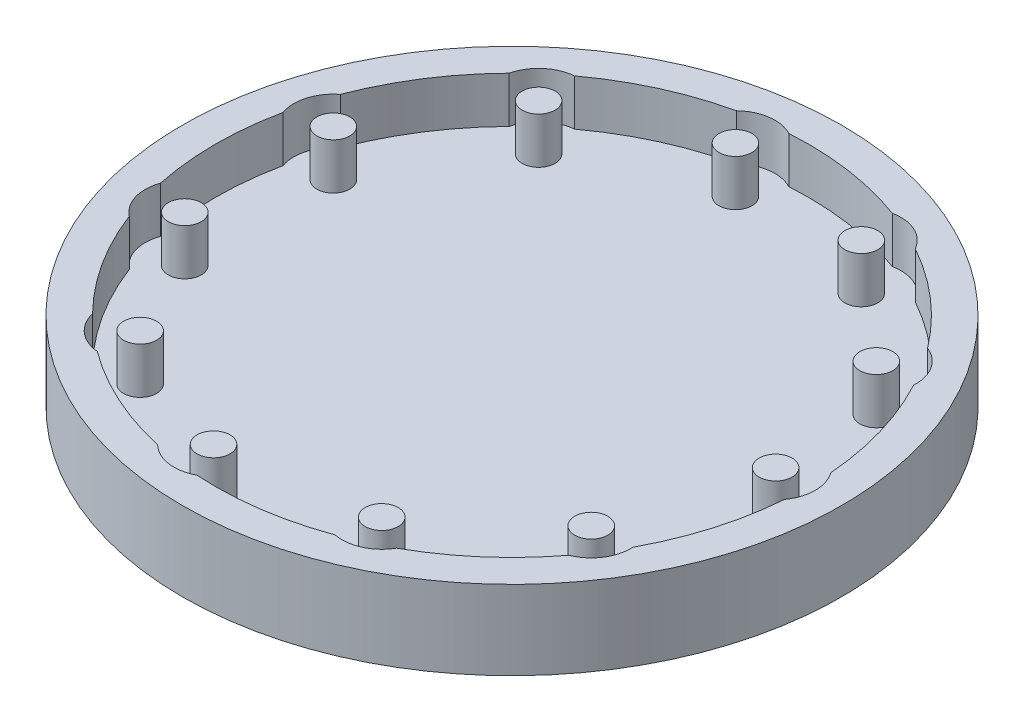
from build123d import *

# Parameters (mm, degrees)
SKETCH2_R           = 50
BOSS_EXTRUDE1_DEPTH = 5
SKETCH3_R           = 2.5
BOSS_EXTRUDE2_DEPTH = 7
SKETCH4_R           = 50
BOSS_EXTRUDE3_DEPTH = 7


with BuildPart() as part:
    # Sketch2 → Boss-Extrude1 (new body)
    with BuildSketch(Plane(origin=(0, 0, 0), x_dir=(1, 0, 0), z_dir=(0, 1, 0))):
        Circle(SKETCH2_R)
    extrude(amount=BOSS_EXTRUDE1_DEPTH)

    # Sketch3 → Boss-Extrude2 (add)
    with BuildSketch(Plane(origin=(0, 5, 0), x_dir=(1, 0, 0), z_dir=(0, 1, 0))):
        with Locations((40, 0)):
            Circle(SKETCH3_R)
        with Locations((33.650141313, -21.625632698)):
            Circle(SKETCH3_R)
        with Locations((16.61660052, -36.385279814)):
            Circle(SKETCH3_R)
        with Locations((-5.692593531, -39.592857675)):
            Circle(SKETCH3_R)
        with Locations((-26.194429358, -30.229982974)):
            Circle(SKETCH3_R)
        with Locations((-38.379718945, -11.269302274)):
            Circle(SKETCH3_R)
        with Locations((-38.379718945, 11.269302274)):
            Circle(SKETCH3_R)
        with Locations((-26.194429358, 30.229982974)):
            Circle(SKETCH3_R)
        with Locations((-5.692593531, 39.592857675)):
            Circle(SKETCH3_R)
        with Locations((16.61660052, 36.385279814)):
            Circle(SKETCH3_R)
        with Locations((33.650141313, 21.625632698)):
            Circle(SKETCH3_R)
    extrude(amount=BOSS_EXTRUDE2_DEPTH)

    # Sketch4 → Boss-Extrude3 (add)
    with BuildSketch(Plane(origin=(0, 5, 0), x_dir=(1, 0, 0), z_dir=(0, 1, 0))):
        Circle(SKETCH4_R)
        with BuildLine():
            ThreePointArc((44.8625, -3.515123575), (46, 0), (44.8625, 3.515123575))
            ThreePointArc((44.8625, 3.515123575), (43.177183813, 12.677965058), (39.6411559, 21.297388547))
            ThreePointArc((39.6411559, 21.297388547), (38.69766251, 24.869477603), (35.840317333, 27.211608799))
            ThreePointArc((35.840317333, 27.211608799), (29.468733028, 34.008730846), (21.834024893, 39.348130286))
            ThreePointArc((21.834024893, 39.348130286), (19.109090598, 41.843071786), (15.439087149, 42.268600497))
            ThreePointArc((15.439087149, 42.268600497), (6.404167722, 44.541964885), (-2.905254746, 44.90611868))
            ThreePointArc((-2.905254746, 44.90611868), (-6.546482561, 45.531786327), (-9.863944118, 43.905610193))
            ThreePointArc((-9.863944118, 43.905610193), (-18.693675585, 40.933439791), (-26.722136531, 36.206731684))
            ThreePointArc((-26.722136531, 36.206731684), (-30.123593761, 34.76448042), (-32.035242822, 31.602898875))
            ThreePointArc((-32.035242822, 31.602898875), (-37.856408977, 24.328836786), (-42.054928776, 16.011963203))
            ThreePointArc((-42.054928776, 16.011963203), (-44.136676786, 12.959697615), (-44.035578281, 9.266490459))
            ThreePointArc((-44.035578281, 9.266490459), (-45, 0), (-44.035578281, -9.266490459))
            ThreePointArc((-44.035578281, -9.266490459), (-44.136676786, -12.959697615), (-42.054928776, -16.011963203))
            ThreePointArc((-42.054928776, -16.011963203), (-37.856408977, -24.328836786), (-32.035242822, -31.602898875))
            ThreePointArc((-32.035242822, -31.602898875), (-30.123593761, -34.76448042), (-26.722136531, -36.206731684))
            ThreePointArc((-26.722136531, -36.206731684), (-18.693675585, -40.933439791), (-9.863944118, -43.905610193))
            ThreePointArc((-9.863944118, -43.905610193), (-6.546482561, -45.531786327), (-2.905254746, -44.90611868))
            ThreePointArc((-2.905254746, -44.90611868), (6.404167722, -44.541964885), (15.439087149, -42.268600497))
            ThreePointArc((15.439087149, -42.268600497), (19.109090598, -41.843071786), (21.834024893, -39.348130286))
            ThreePointArc((21.834024893, -39.348130286), (29.468733028, -34.008730846), (35.840317333, -27.211608799))
            ThreePointArc((35.840317333, -27.211608799), (38.69766251, -24.869477603), (39.6411559, -21.297388547))
            ThreePointArc((39.6411559, -21.297388547), (43.177183813, -12.677965058), (44.8625, -3.515123575))
        make_face(mode=Mode.SUBTRACT)
    extrude(amount=BOSS_EXTRUDE3_DEPTH)


solid = part.part
